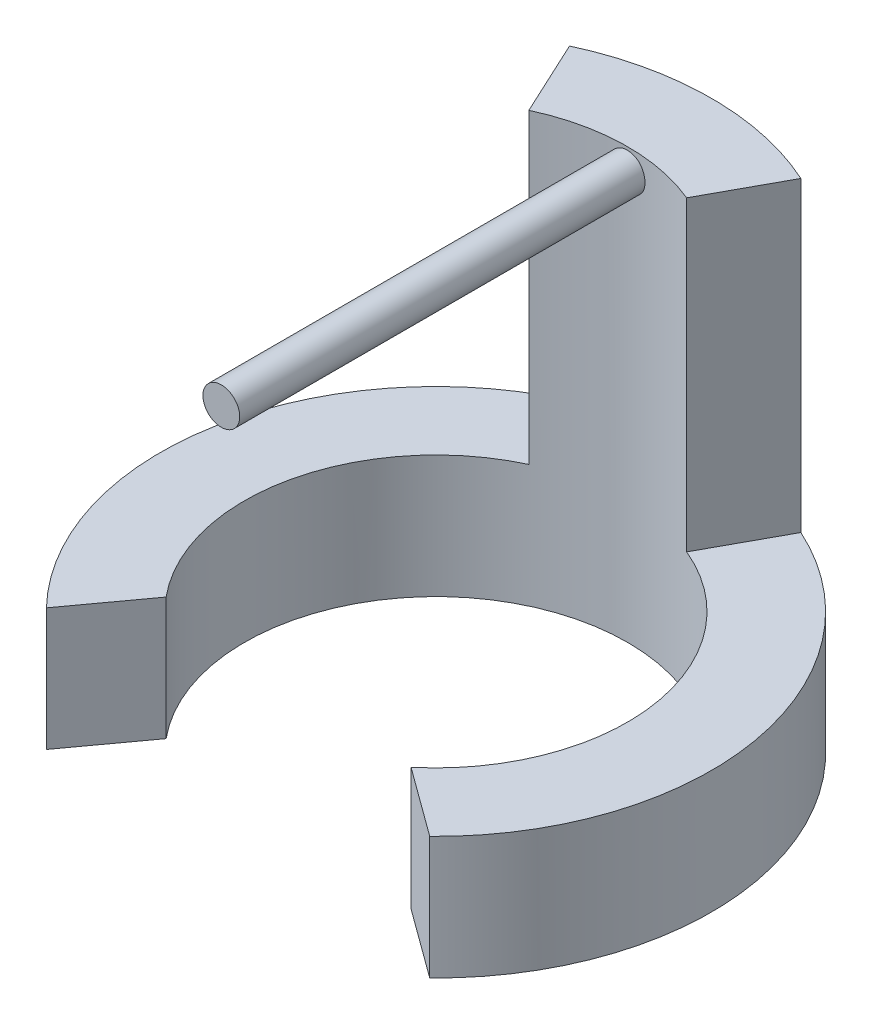
from build123d import *

# Parameters (mm, degrees)
BOSS_EXTRUDE1_DEPTH      = 10.16
BOSS_EXTRUDE2_DEPTH      = 25.4
SKETCH10_R               = 1.524
BOSS_EXTRUDE3_DEPTH      = 17.78
BOSS_EXTRUDE3_DEPTH_BACK = 17.78


with BuildPart() as part:
    # Sketch1 → Boss-Extrude1 (new body)
    with BuildSketch(Plane(origin=(0, 0, 0), x_dir=(1, 0, 0), z_dir=(0, 1, 0))):
        with BuildLine():
            Line((-16.392571649, -15.875), (-12.210897172, -10.144437651))
            ThreePointArc((-12.210897172, -10.144437651), (1.461207541, 15.807608849), (10.144437651, -12.210897172))
            Line((10.144437651, -12.210897172), (15.875, -16.392571649))
            ThreePointArc((15.875, -16.392571649), (0.365978423, 22.816618725), (-16.392571649, -15.875))
        make_face()
    extrude(amount=BOSS_EXTRUDE1_DEPTH)

    # Sketch5 → Boss-Extrude2 (add)
    with BuildSketch(Plane(origin=(0, 10.16, 0), x_dir=(1, 0, 0), z_dir=(0, 1, 0))):
        with BuildLine():
            Line((-9.628733509, 20.688632658), (-6.698472134, 14.392570864))
            ThreePointArc((-6.698472134, 14.392570864), (-0.320626088, 15.87176184), (6.111754726, 14.651350763))
            Line((6.111754726, 14.651350763), (9.450800874, 20.770517401))
            ThreePointArc((9.450800874, 20.770517401), (-0.097935098, 22.819343526), (-9.628733509, 20.688632658))
        make_face()
    extrude(amount=BOSS_EXTRUDE2_DEPTH)


with BuildPart() as body_2:
    # Sketch10 → Boss-Extrude3 (new body, two sides)
    with BuildSketch(Plane.XY) as boss_extrude3_sk:
        with Locations((0, 33.782)):
            Circle(SKETCH10_R)
    extrude(amount=BOSS_EXTRUDE3_DEPTH)
    extrude(boss_extrude3_sk.sketch, amount=-BOSS_EXTRUDE3_DEPTH_BACK)


solid = Compound([part.part, body_2.part])
